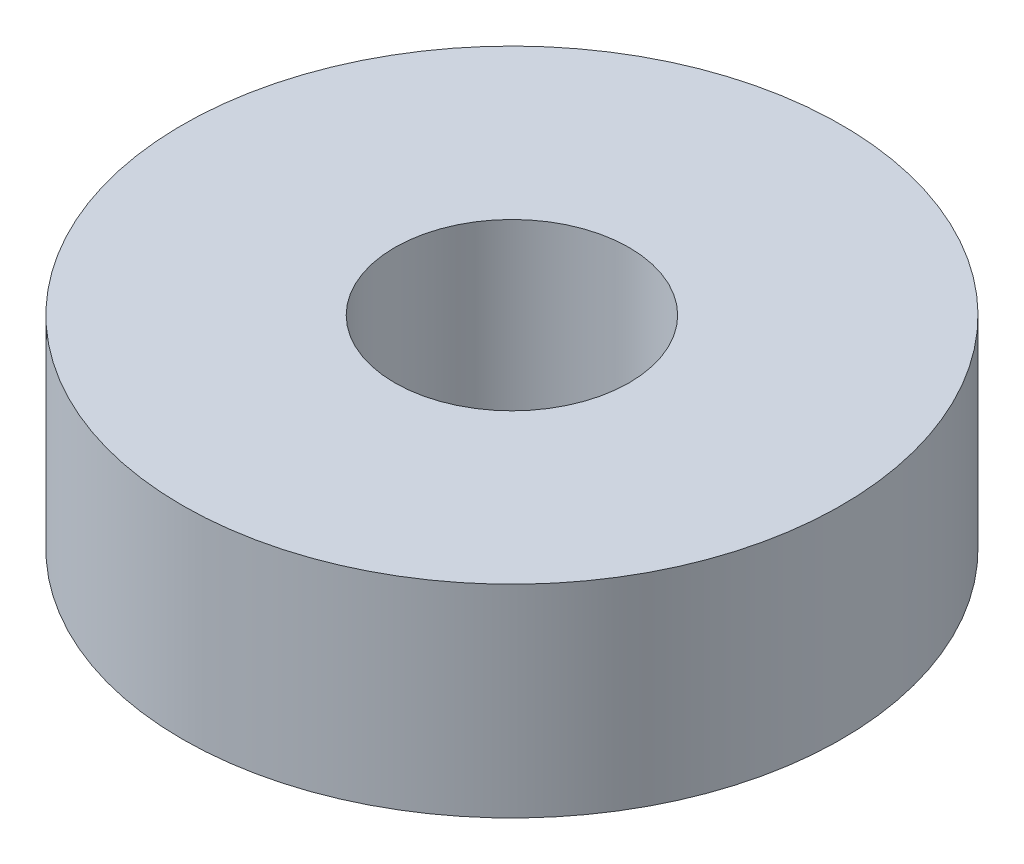
from build123d import *

# Parameters (mm, degrees)
SKETCH1_R           = 10.825
SKETCH1_R_2         = 3.85
BOSS_EXTRUDE1_DEPTH = 6.65


with BuildPart() as part:
    # Sketch1 → Boss-Extrude1 (new body)
    with BuildSketch(Plane(origin=(0, 0, 0), x_dir=(1, 0, 0), z_dir=(0, 1, 0))):
        Circle(SKETCH1_R)
        Circle(SKETCH1_R_2, mode=Mode.SUBTRACT)
    extrude(amount=BOSS_EXTRUDE1_DEPTH)


solid = part.part
